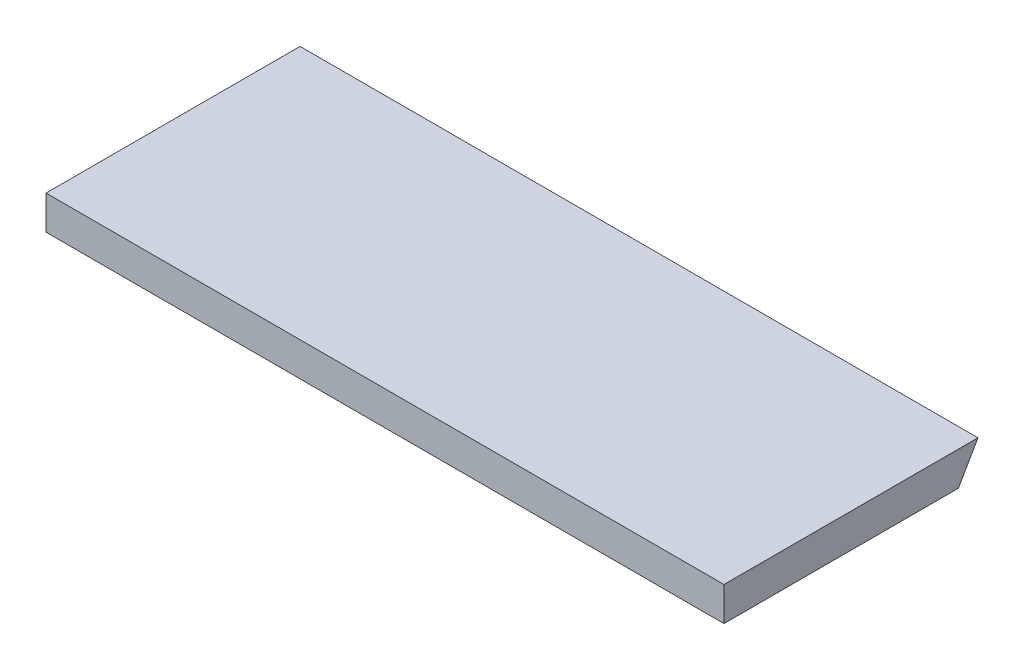
from build123d import *

# Parameters (mm, degrees)
SKETCH1_W               = 123
SKETCH1_H               = 12
BOSS_EXTRUDE1_DEPTH     = 240
CUT_EXTRUDE1_DEPTH      = 1
CUT_EXTRUDE1_DEPTH_BACK = 241


with BuildPart() as part:
    # Sketch1 → Boss-Extrude1 (new body)
    with BuildSketch(Plane(origin=(0, 0, 0), x_dir=(0, 0, -1), z_dir=(1, 0, 0))):
        with Locations((73.5, -6)):
            Rectangle(SKETCH1_W, SKETCH1_H)
    extrude(amount=-BOSS_EXTRUDE1_DEPTH)

    # Sketch2 → Cut-Extrude1 (cut, two sides)
    with BuildSketch(Plane(origin=(0, -198.236323208, -222.140507253), x_dir=(0, 0, -1), z_dir=(1, 0, 0))) as cut_extrude1_sk:
        Polygon((-429.320437804, -337.154669534), (-215.412171162, 33.34531645), (-115.125850584, 207.046318995), (98.782416059, 577.546304979), (839.782388026, 149.729771694), (311.679534163, -764.971202819), align=None)
    extrude(amount=CUT_EXTRUDE1_DEPTH, mode=Mode.SUBTRACT)
    extrude(cut_extrude1_sk.sketch, amount=-CUT_EXTRUDE1_DEPTH_BACK, mode=Mode.SUBTRACT)


solid = part.part
